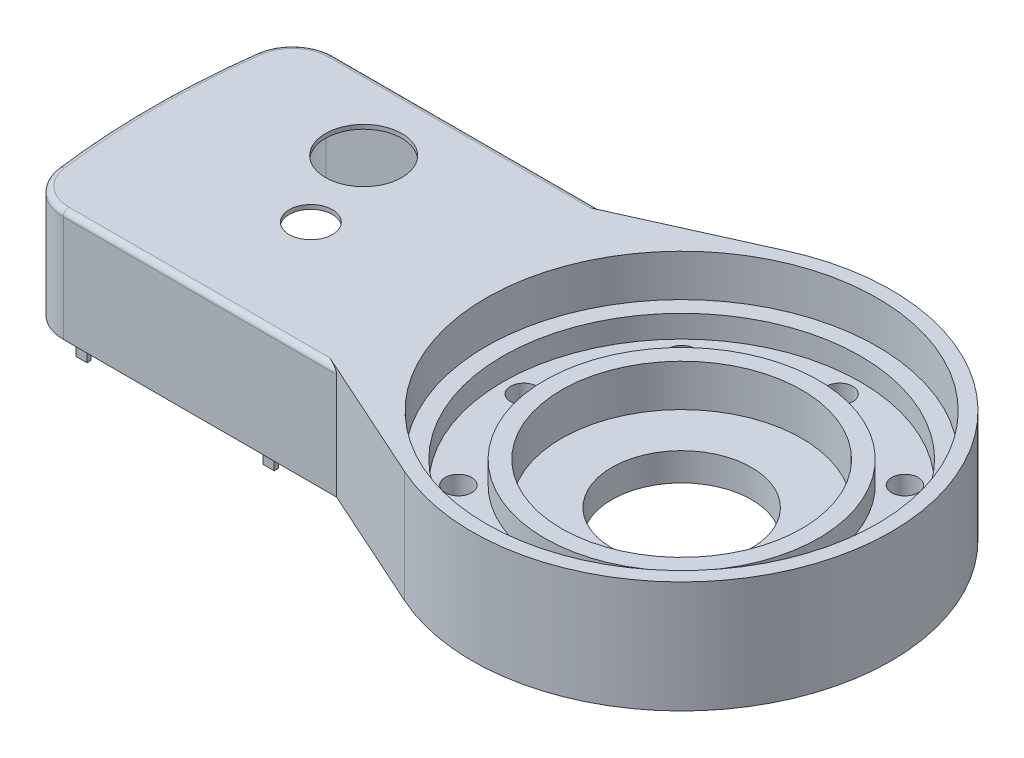
from build123d import *

# Parameters (mm, degrees)
BOSS_EXTRUDE1_DEPTH = 40
SKETCH2_R           = 70
CUT_EXTRUDE1_DEPTH  = 15
SKETCH3_R           = 64
SKETCH3_R_2         = 49
CUT_EXTRUDE3_DEPTH  = 8
SKETCH4_R           = 4.75
CUT_EXTRUDE4_DEPTH  = 18
SKETCH5_R           = 25
CUT_EXTRUDE5_DEPTH  = 26
SKETCH7_R           = 43
CUT_EXTRUDE6_DEPTH  = 15
CUT_EXTRUDE7_DEPTH  = 38.5
SKETCH9_R           = 13.664776458
SKETCH9_R_2         = 7.722805547
CUT_EXTRUDE8_DEPTH  = 41
FILLET1_R           = 2
SKETCH10_W          = 4
SKETCH10_H          = 9
BOSS_EXTRUDE2_DEPTH = 1.5
SKETCH11_R          = 2
CUT_EXTRUDE9_DEPTH  = 4


with BuildPart() as part:
    # Sketch1 → Boss-Extrude1 (new body)
    with BuildSketch(Plane(origin=(0, 0, 0), x_dir=(1, 0, 0), z_dir=(0, 1, 0))):
        with BuildLine():
            Line((-257.832794656, 48.5), (-160, 48.5))
            Line((-160, 48.5), (-115.769532107, 68.397630762))
            ThreePointArc((-115.769532107, 68.397630762), (-10, 0), (-115.769532107, -68.397630762))
            Line((-115.769532107, -68.397630762), (-160, -48.5))
            Line((-160, -48.5), (-257.832794656, -48.5))
            ThreePointArc((-257.832794656, -48.5), (-267.732532415, -44.769214361), (-272.707763578, -35.432692308))
            ThreePointArc((-272.707763578, -35.432692308), (-275, 0), (-272.707763578, 35.432692308))
            ThreePointArc((-272.707763578, 35.432692308), (-267.732532415, 44.769214361), (-257.832794656, 48.5))
        make_face()
    extrude(amount=BOSS_EXTRUDE1_DEPTH)

    # Sketch2 → Cut-Extrude1 (cut)
    with BuildSketch(Plane(origin=(0, 40, 0), x_dir=(1, 0, 0), z_dir=(0, 1, 0))):
        with Locations((-85, 0)):
            Circle(SKETCH2_R)
    extrude(amount=-CUT_EXTRUDE1_DEPTH, mode=Mode.SUBTRACT)

    # Sketch3 → Cut-Extrude3 (cut)
    with BuildSketch(Plane(origin=(0, 25, 0), x_dir=(1, 0, 0), z_dir=(0, 1, 0))):
        with Locations((-85, 0)):
            Circle(SKETCH3_R)
        with Locations((-85, 0)):
            Circle(SKETCH3_R_2, mode=Mode.SUBTRACT)
    extrude(amount=-CUT_EXTRUDE3_DEPTH, mode=Mode.SUBTRACT)

    # Sketch4 → Cut-Extrude4 (cut, through all)
    with BuildSketch(Plane(origin=(0, 17, 0), x_dir=(1, 0, 0), z_dir=(0, 1, 0))):
        with Locations((-45.048466863, -39.951533137)):
            Circle(SKETCH4_R)
        with Locations((-85, -56.5)):
            Circle(SKETCH4_R)
        with Locations((-28.5, 0)):
            Circle(SKETCH4_R)
        with Locations((-124.951533137, -39.951533137)):
            Circle(SKETCH4_R)
        with Locations((-141.5, 0)):
            Circle(SKETCH4_R)
        with Locations((-124.951533137, 39.951533137)):
            Circle(SKETCH4_R)
        with Locations((-85, 56.5)):
            Circle(SKETCH4_R)
        with Locations((-45.048466863, 39.951533137)):
            Circle(SKETCH4_R)
    extrude(amount=-CUT_EXTRUDE4_DEPTH, mode=Mode.SUBTRACT)

    # Sketch5 → Cut-Extrude5 (cut, through all)
    with BuildSketch(Plane(origin=(0, 25, 0), x_dir=(1, 0, 0), z_dir=(0, 1, 0))):
        with Locations((-85, 0)):
            Circle(SKETCH5_R)
    extrude(amount=-CUT_EXTRUDE5_DEPTH, mode=Mode.SUBTRACT)

    # Sketch7 → Cut-Extrude6 (cut)
    with BuildSketch(Plane(origin=(0, 25, 0), x_dir=(1, 0, 0), z_dir=(0, 1, 0))):
        with Locations((-85, 0)):
            Circle(SKETCH7_R)
    extrude(amount=-CUT_EXTRUDE6_DEPTH, mode=Mode.SUBTRACT)

    # Sketch8 → Cut-Extrude7 (cut)
    with BuildSketch(Plane.XZ):
        with BuildLine():
            Line((-257.832794656, 45.5), (-160, 45.5))
            Line((-160, 45.5), (-160, -45.5))
            Line((-160, -45.5), (-257.832794656, -45.5))
            ThreePointArc((-257.832794656, -45.5), (-265.752584863, -42.515371489), (-269.732769794, -35.046153846))
            ThreePointArc((-269.732769794, -35.046153846), (-272, 0), (-269.732769794, 35.046153846))
            ThreePointArc((-269.732769794, 35.046153846), (-265.752584863, 42.515371489), (-257.832794656, 45.5))
        make_face()
    extrude(amount=-CUT_EXTRUDE7_DEPTH, mode=Mode.SUBTRACT)

    # Sketch9 → Cut-Extrude8 (cut, through all)
    with BuildSketch(Plane(origin=(0, 40, 0), x_dir=(1, 0, 0), z_dir=(0, 1, 0))):
        with Locations((-221.059573663, 22.236353901)):
            Circle(SKETCH9_R)
        with Locations((-209.874820802, -7.855957366)):
            Circle(SKETCH9_R_2)
    extrude(amount=-CUT_EXTRUDE8_DEPTH, mode=Mode.SUBTRACT)

    # Fillet1
    fillet1_edges = [part.edges().sort_by_distance(p)[0] for p in [
        (-267.732532415, 40, 44.769214361),
        (-208.916397328, 40, 48.5),
        (-208.916397328, 40, -48.5),
        (-267.732532415, 40, -44.769214361),
        (-275, 40, 0),
    ]]
    fillet(fillet1_edges, radius=FILLET1_R)

    # Sketch10 → Boss-Extrude2 (add)
    with BuildSketch(Plane.XY.offset(-45.5)):
        with Locations((-252.832794656, 0)):
            Rectangle(SKETCH10_W, SKETCH10_H)
        with Locations((-185.832794656, 0)):
            Rectangle(SKETCH10_W, SKETCH10_H)
    boss_extrude2 = extrude(amount=-BOSS_EXTRUDE2_DEPTH)

    # Mirror1: Boss-Extrude2 across plane
    add(boss_extrude2.mirror(Plane.XY))

    # Sketch11 → Cut-Extrude9 (cut)
    with BuildSketch(Plane.XZ):
        with Locations((-106, 21)):
            Circle(SKETCH11_R)
        with Locations((-64, 21)):
            Circle(SKETCH11_R)
        with Locations((-64, -21)):
            Circle(SKETCH11_R)
        with Locations((-106, -21)):
            Circle(SKETCH11_R)
    extrude(amount=-CUT_EXTRUDE9_DEPTH, mode=Mode.SUBTRACT)


solid = part.part
